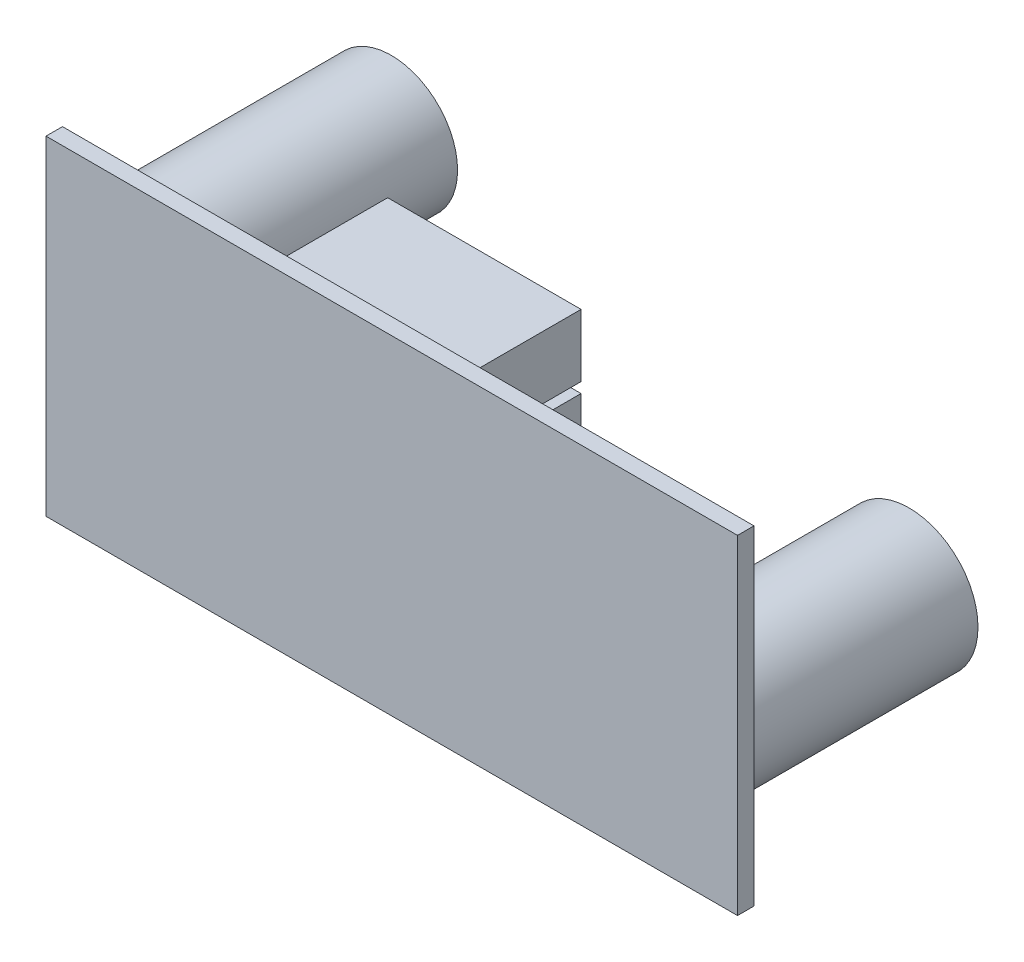
from build123d import *

# Parameters (mm, degrees)
SKETCH1_W           = 42
SKETCH1_H           = 20
BOSS_EXTRUDE1_DEPTH = 1
SKETCH2_R           = 4.027938591
SKETCH2_R_2         = 4.182706726
BOSS_EXTRUDE2_DEPTH = 15
SKETCH3_W           = 11.745093392
SKETCH3_H           = 3.800746796
SKETCH3_W_2         = 11.743469105
SKETCH3_H_2         = 12.98355877
BOSS_EXTRUDE3_DEPTH = 7


with BuildPart() as part:
    # Sketch1 → Boss-Extrude1 (new body)
    with BuildSketch(Plane.XY):
        with Locations((-4.931174089, -4.708502024)):
            Rectangle(SKETCH1_W, SKETCH1_H)
    extrude(amount=BOSS_EXTRUDE1_DEPTH)

    # Sketch2 → Boss-Extrude2 (add)
    with BuildSketch(Plane.XY):
        with Locations((-20.961145163, 0)):
            Circle(SKETCH2_R)
        with Locations((10.49307608, -8.234663003)):
            Circle(SKETCH2_R_2)
    extrude(amount=-BOSS_EXTRUDE2_DEPTH)

    # Sketch3 → Boss-Extrude3 (add)
    with BuildSketch(Plane.XY):
        with Locations((-7.305637446, 2.527727406)):
            Rectangle(SKETCH3_W, SKETCH3_H)
        with Locations((-7.30644959, -6.491779385)):
            Rectangle(SKETCH3_W_2, SKETCH3_H_2)
    extrude(amount=-BOSS_EXTRUDE3_DEPTH)


solid = part.part
